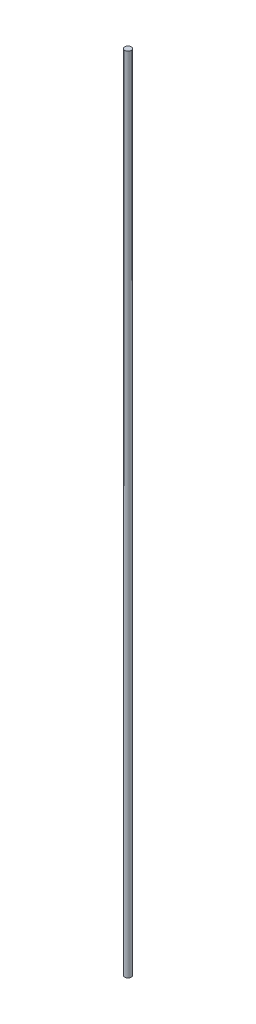
from build123d import *

# Parameters (mm, degrees)
SKETCH1_R           = 4
BOSS_EXTRUDE1_DEPTH = 1000


with BuildPart() as part:
    # Sketch1 → Boss-Extrude1 (new body)
    with BuildSketch(Plane(origin=(0, 0, 0), x_dir=(1, 0, 0), z_dir=(0, 1, 0))):
        Circle(SKETCH1_R)
    extrude(amount=BOSS_EXTRUDE1_DEPTH)


solid = part.part
